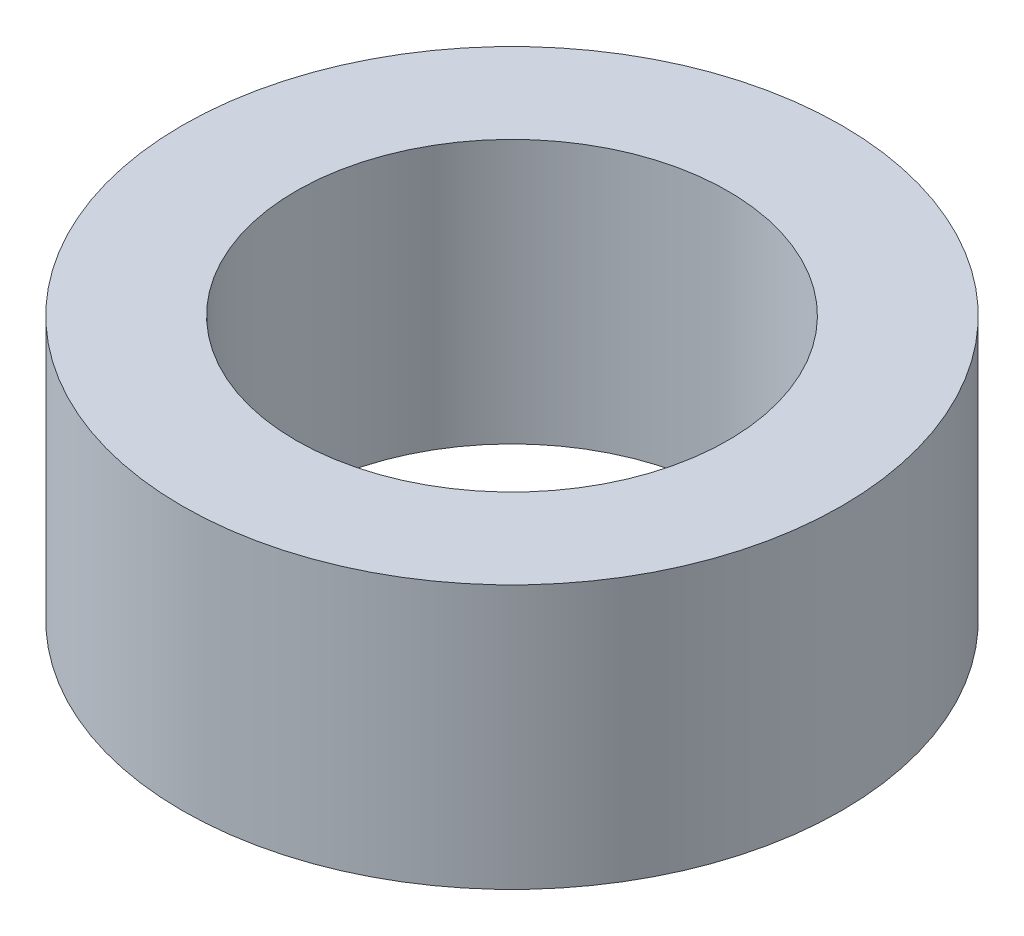
from build123d import *

# Parameters (mm, degrees)
SKETCH1_R           = 3.96875
SKETCH1_R_2         = 2.6
BOSS_EXTRUDE1_DEPTH = 3.175


with BuildPart() as part:
    # Sketch1 → Boss-Extrude1 (new body)
    with BuildSketch(Plane(origin=(0, 0, 0), x_dir=(1, 0, 0), z_dir=(0, 1, 0))):
        Circle(SKETCH1_R)
        Circle(SKETCH1_R_2, mode=Mode.SUBTRACT)
    extrude(amount=BOSS_EXTRUDE1_DEPTH)


solid = part.part
